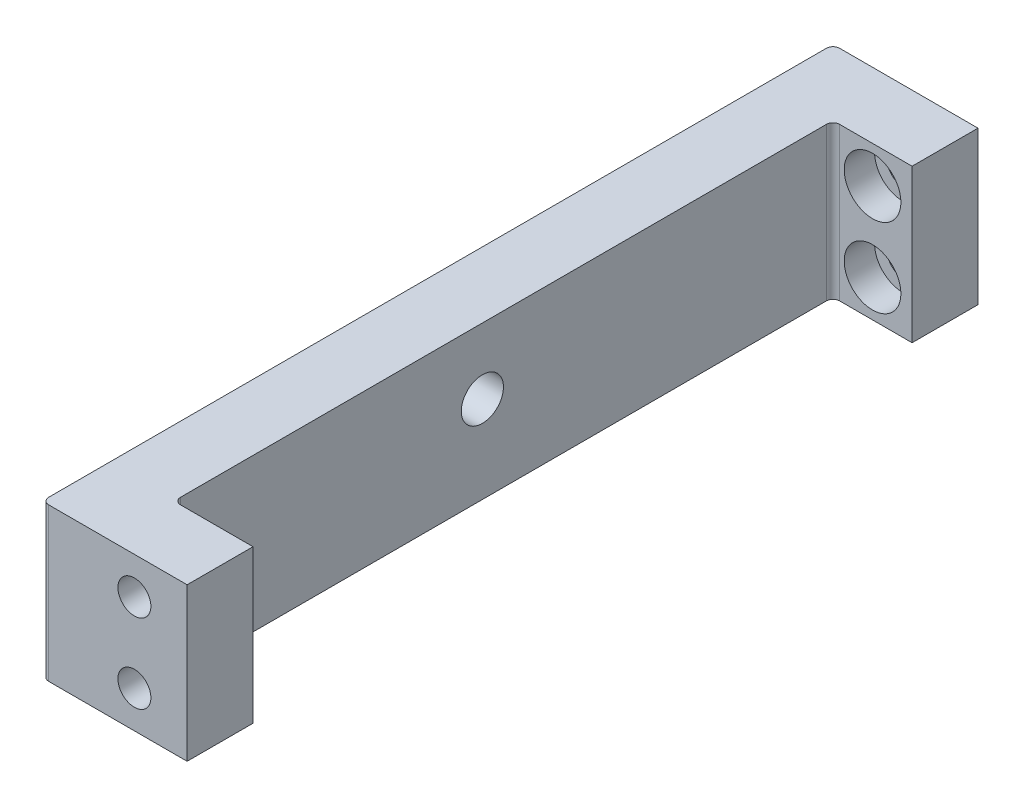
from build123d import *

# Parameters (mm, degrees)
SKETCH_1_W                  = 5
SKETCH_1_H                  = 11.6
EXTRUDE_1_DEPTH             = 30
SKETCH_2_W                  = 5
SKETCH_2_H                  = 11.6
EXTRUDE_2_DEPTH             = 6
HOLE_WIZARD_M3_1_D          = 2.5
HOLE_WIZARD_M3_1_DEPTH      = 7.5
HOLE_WIZARD_M3_1_TIP        = 0.751075774
HOLE_WIZARD_1_D             = 2.4
HOLE_WIZARD_1_DEPTH         = 7.5
HOLE_WIZARD_1_CBORE_D       = 4.3
HOLE_WIZARD_1_CBORE_DEPTH   = 2.3
HOLE_WIZARD_1_TIP           = 0.721032743
FILLET_1_R                  = 0.5
HOLE_WIZARD_3_2_3_2_1_D     = 3.2
HOLE_WIZARD_3_2_3_2_1_DEPTH = 5.2
HOLE_WIZARD_3_2_3_2_1_TIP   = 0.96137699
HOLE_WIZARD_M2_1_D          = 1.6
HOLE_WIZARD_M2_1_DEPTH      = 5.2
HOLE_WIZARD_M2_1_TIP        = 0.480688495


with BuildPart() as part:
    # 草图1 → 凸台-拉伸1 (new body, symmetric)
    with BuildSketch(Plane.XY):
        Rectangle(SKETCH_1_W, SKETCH_1_H)
    extrude(amount=EXTRUDE_1_DEPTH, both=True)

    # 草图2 → 凸台-拉伸2 (add)
    with BuildSketch(Plane(origin=(2.5, 0, 0), x_dir=(0, 0, -1), z_dir=(1, 0, 0))):
        with Locations((-27.5, 0)):
            Rectangle(SKETCH_2_W, SKETCH_2_H)
    extrude_2 = extrude(amount=EXTRUDE_2_DEPTH)

    # 镜向1: 凸台-拉伸2 across plane
    add(extrude_2.mirror(Plane.XY))

    # M3 螺纹孔1
    with Locations(Plane.XY.offset(30)):
        with Locations((4.5, -3), (4.5, 3)):
            Hole(HOLE_WIZARD_M3_1_D / 2, depth=HOLE_WIZARD_M3_1_DEPTH)
            with Locations((0, 0, -(HOLE_WIZARD_M3_1_DEPTH + HOLE_WIZARD_M3_1_TIP / 2))):  # 118° drill point
                Cone(0, HOLE_WIZARD_M3_1_D / 2, HOLE_WIZARD_M3_1_TIP, mode=Mode.SUBTRACT)

    # 打孔尺寸(%根据)内六角圆柱头螺钉的类型1
    with Locations(Plane.XY.offset(-25)):
        with Locations((5.5, -3), (5.5, 3)):
            CounterBoreHole(HOLE_WIZARD_1_D / 2, HOLE_WIZARD_1_CBORE_D / 2, HOLE_WIZARD_1_CBORE_DEPTH, depth=HOLE_WIZARD_1_DEPTH)
            with Locations((0, 0, -(HOLE_WIZARD_1_DEPTH + HOLE_WIZARD_1_TIP / 2))):  # 118° drill point
                Cone(0, HOLE_WIZARD_1_D / 2, HOLE_WIZARD_1_TIP, mode=Mode.SUBTRACT)

    # 圆角1
    fillet_1_edges = [part.edges().sort_by_distance(p)[0] for p in [
        (2.5, 0, 25),
        (2.5, 0, -25),
        (-2.5, 0, 30),
        (-2.5, 0, -30),
    ]]
    fillet(fillet_1_edges, radius=FILLET_1_R)

    # Ø3.2 (3.2) 直径孔1
    with Locations(Plane.ZY.offset(2.5)):
        with Locations((1.6, 0.8)):
            Hole(HOLE_WIZARD_3_2_3_2_1_D / 2, depth=HOLE_WIZARD_3_2_3_2_1_DEPTH)
            with Locations((0, 0, -(HOLE_WIZARD_3_2_3_2_1_DEPTH + HOLE_WIZARD_3_2_3_2_1_TIP / 2))):  # 118° drill point
                Cone(0, HOLE_WIZARD_3_2_3_2_1_D / 2, HOLE_WIZARD_3_2_3_2_1_TIP, mode=Mode.SUBTRACT)

    # M2 螺纹孔1
    with Locations(Plane(origin=(0, -5.8, 0), x_dir=(-1, 0, 0), z_dir=(0, -1, 0))):
        with Locations((-0.325, 9)):
            Hole(HOLE_WIZARD_M2_1_D / 2, depth=HOLE_WIZARD_M2_1_DEPTH)
            with Locations((0, 0, -(HOLE_WIZARD_M2_1_DEPTH + HOLE_WIZARD_M2_1_TIP / 2))):  # 118° drill point
                Cone(0, HOLE_WIZARD_M2_1_D / 2, HOLE_WIZARD_M2_1_TIP, mode=Mode.SUBTRACT)


solid = part.part
